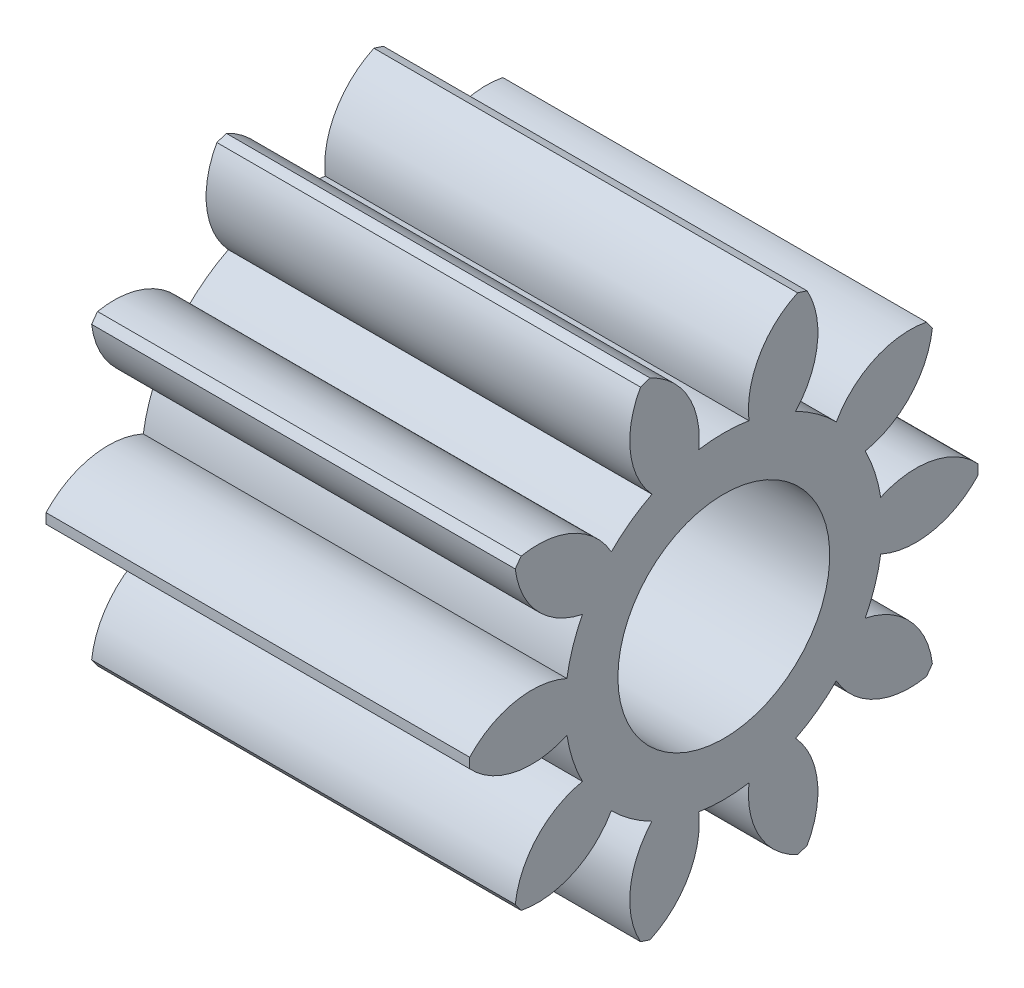
from build123d import *

# Parameters (mm, degrees)
BASPROSKE_W     = 10
BASPROSKE_H     = 6
TOOTHCUT_DEPTH  = 14.114877049
TEETHCUTS_COUNT = 10
TEETHCUTS_ANGLE = 324
BORSKE_R        = 2.5
BORE_DEPTH      = 50.0000508


with BuildPart() as part:
    # BasProSke → Base-Revolve (revolve)
    with BuildSketch(Plane(origin=(0, 0, 0), x_dir=(1, 0, 0), z_dir=(0, 1, 0)), mode=Mode.PRIVATE) as base_revolve_sk:
        with Locations((5, 3)):
            Rectangle(BASPROSKE_W, BASPROSKE_H)
    revolve(base_revolve_sk.sketch.rotate(Axis((-10, 0, 0), (1, 0, 0)), 180), axis=Axis((-10, 0, 0), (1, 0, 0)))

    # TooCutSke → ToothCut (cut, through all)
    with BuildSketch(Plane(origin=(0, 0, 0), x_dir=(0, 0, -1), z_dir=(1, 0, 0))):
        with BuildLine():
            ThreePointArc((0.59278292, 3.701838653), (0, 3.749), (-0.59278292, 3.701838653))
            ThreePointArc((-0.59278292, 3.701838653), (-0.846593509, 4.924114224), (-1.775771316, 5.757784417))
            ThreePointArc((-1.775771316, 5.757784417), (0, 6.0254), (1.775771316, 5.757784417))
            ThreePointArc((1.775771316, 5.757784417), (0.846593509, 4.924114224), (0.59278292, 3.701838653))
        make_face()
    toothcut = extrude(amount=TOOTHCUT_DEPTH, mode=Mode.SUBTRACT)

    # TeethCuts: ToothCut ×10 about axis
    teethcuts_axis = Axis((-10, 0, 0), (1, 0, 0))
    for i in range(1, TEETHCUTS_COUNT):
        add(toothcut.rotate(teethcuts_axis, i * TEETHCUTS_ANGLE / (TEETHCUTS_COUNT - 1)), mode=Mode.SUBTRACT)

    # BorSke → Bore (cut, symmetric)
    with BuildSketch(Plane(origin=(0, 0, 0), x_dir=(0, 0, -1), z_dir=(1, 0, 0))):
        with Locations(Location((0, 0, 0), (0, 0, 180))):
            Circle(BORSKE_R)
    extrude(amount=BORE_DEPTH, both=True, mode=Mode.SUBTRACT)


solid = part.part
